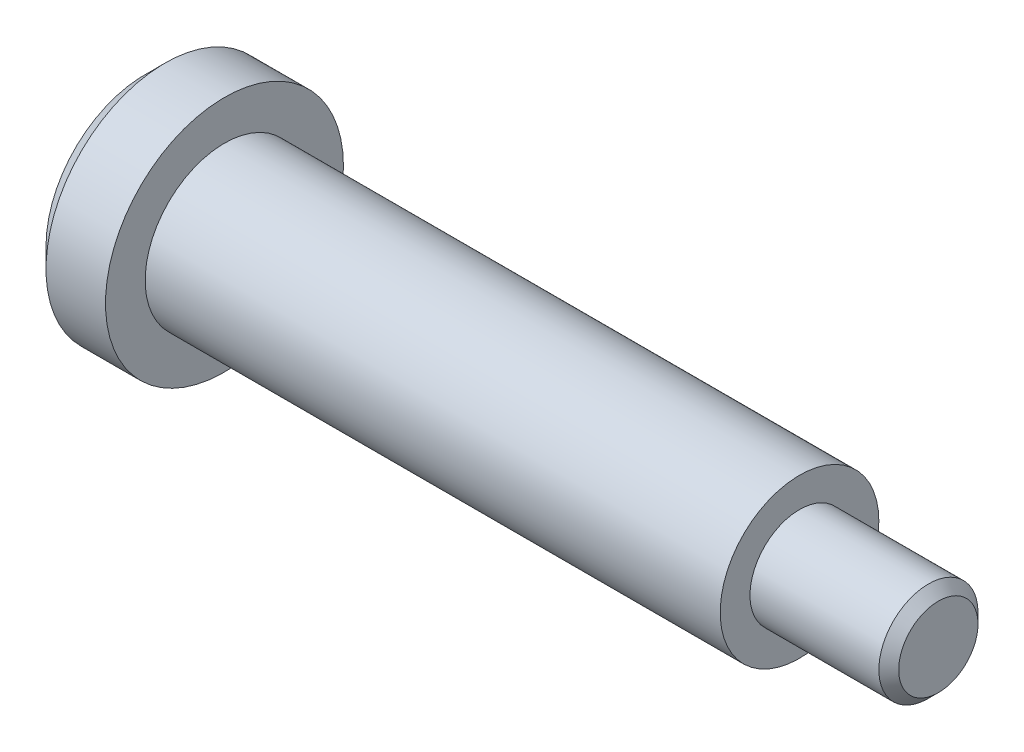
from build123d import *

# Parameters (mm, degrees)
SKETCH1_R           = 6
BOSS_EXTRUDE1_DEPTH = 4
SKETCH2_R           = 4
BOSS_EXTRUDE2_DEPTH = 29
SKETCH3_R           = 2.5
BOSS_EXTRUDE3_DEPTH = 7
CHAMFER1_SIZE       = 0.5
CHAMFER2_SIZE       = 1
SKETCH4_R           = 2.5
CUT_EXTRUDE1_DEPTH  = 1
FILLET1_R           = 0.5
SCALE1_SCALE        = 0.5


with BuildPart() as part:
    # Sketch1 → Boss-Extrude1 (new body)
    with BuildSketch(Plane(origin=(0, 0, 0), x_dir=(0, 0, -1), z_dir=(1, 0, 0))):
        Circle(SKETCH1_R)
    extrude(amount=BOSS_EXTRUDE1_DEPTH)

    # Sketch2 → Boss-Extrude2 (add)
    with BuildSketch(Plane(origin=(4, 0, 0), x_dir=(0, 0, -1), z_dir=(1, 0, 0))):
        Circle(SKETCH2_R)
    extrude(amount=BOSS_EXTRUDE2_DEPTH)

    # Sketch3 → Boss-Extrude3 (add)
    with BuildSketch(Plane(origin=(33, 0, 0), x_dir=(0, 0, -1), z_dir=(1, 0, 0))):
        Circle(SKETCH3_R)
    extrude(amount=BOSS_EXTRUDE3_DEPTH)

    # Chamfer1
    chamfer1_edges = [part.edges().sort_by_distance(p)[0] for p in [
        (40, 0, 2.5),
    ]]
    chamfer(chamfer1_edges, length=CHAMFER1_SIZE)

    # Chamfer2
    chamfer2_edges = [part.edges().sort_by_distance(p)[0] for p in [
        (0, 0, 6),
    ]]
    chamfer(chamfer2_edges, length=CHAMFER2_SIZE)

    # Sketch4 → Cut-Extrude1 (cut)
    with BuildSketch(Plane.ZY):
        Circle(SKETCH4_R)
    extrude(amount=-CUT_EXTRUDE1_DEPTH, mode=Mode.SUBTRACT)

    # Fillet1
    fillet1_edges = [part.edges().sort_by_distance(p)[0] for p in [
        (0, 0, -2.5),
    ]]
    fillet(fillet1_edges, radius=FILLET1_R)


with BuildPart() as part_1:
    # Scale1: scaled about (0, 0, 0)
    add(part.part.scale(SCALE1_SCALE))


solid = part_1.part
